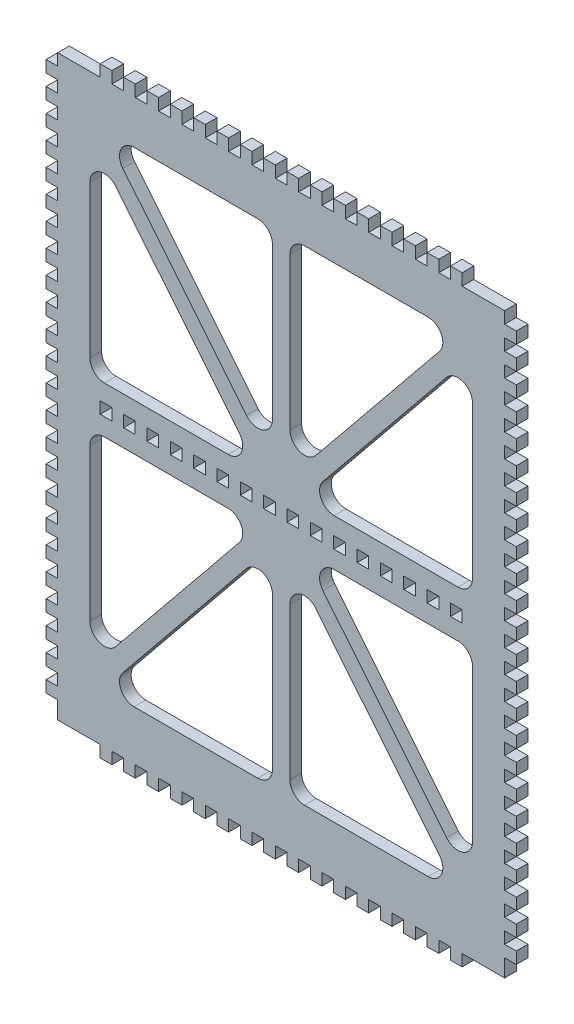
from build123d import *

# Parameters (mm, degrees)
SKETCH1_W           = 161.12
SKETCH1_H           = 198
BOSS_EXTRUDE1_DEPTH = 4
SKETCH2_W           = 4
SKETCH2_H           = 4
SKETCH2_H_2         = 6
CUT_EXTRUDE1_DEPTH  = 4
SKETCH3_W           = 4
SKETCH3_H           = 4
BOSS_EXTRUDE2_DEPTH = 4
SKETCH4_W           = 4
SKETCH4_H           = 4
CUT_EXTRUDE2_DEPTH  = 10


with BuildPart() as part:
    # Sketch1 → Boss-Extrude1 (new body)
    with BuildSketch(Plane.XY):
        with Locations((0, -1)):
            Rectangle(SKETCH1_W, SKETCH1_H)
        with BuildLine():
            Line((-50.394942081, 83), (-8, 83))
            ThreePointArc((-8, 83), (-4.464466094, 81.535533906), (-3, 78))
            Line((-3, 78), (-3, 25.860074887))
            ThreePointArc((-3, 25.860074887), (-6.326255466, 21.148538064), (-11.879431694, 22.705711285))
            Line((-11.879431694, 22.705711285), (-54.274373775, 74.845636398))
            ThreePointArc((-54.274373775, 74.845636398), (-54.910017829, 80.148043527), (-50.394942081, 83))
        make_face(mode=Mode.SUBTRACT)
        with BuildLine():
            Line((-56.680568306, 68.294288715), (-14.285626225, 16.154363602))
            ThreePointArc((-14.285626225, 16.154363602), (-13.649982171, 10.851956473), (-18.165057919, 8))
            Line((-18.165057919, 8), (-60.56, 8))
            ThreePointArc((-60.56, 8), (-64.095533906, 9.464466094), (-65.56, 13))
            Line((-65.56, 13), (-65.56, 65.139925113))
            ThreePointArc((-65.56, 65.139925113), (-62.233744534, 69.851461936), (-56.680568306, 68.294288715))
        make_face(mode=Mode.SUBTRACT)
        with BuildLine():
            Line((8, 83), (50.394942081, 83))
            ThreePointArc((50.394942081, 83), (54.910017829, 80.148043527), (54.274373775, 74.845636398))
            Line((54.274373775, 74.845636398), (11.879431694, 22.705711285))
            ThreePointArc((11.879431694, 22.705711285), (6.326255466, 21.148538064), (3, 25.860074887))
            Line((3, 25.860074887), (3, 78))
            ThreePointArc((3, 78), (4.464466094, 81.535533906), (8, 83))
        make_face(mode=Mode.SUBTRACT)
        with BuildLine():
            Line((56.680568306, 68.294288715), (14.285626225, 16.154363602))
            ThreePointArc((14.285626225, 16.154363602), (13.649982171, 10.851956473), (18.165057919, 8))
            Line((18.165057919, 8), (60.56, 8))
            ThreePointArc((60.56, 8), (64.095533906, 9.464466094), (65.56, 13))
            Line((65.56, 13), (65.56, 65.139925113))
            ThreePointArc((65.56, 65.139925113), (62.233744534, 69.851461936), (56.680568306, 68.294288715))
        make_face(mode=Mode.SUBTRACT)
        with BuildLine():
            Line((-65.56, -13), (-65.56, -65.139925113))
            ThreePointArc((-65.56, -65.139925113), (-62.233744534, -69.851461936), (-56.680568306, -68.294288715))
            Line((-56.680568306, -68.294288715), (-14.285626225, -16.154363602))
            ThreePointArc((-14.285626225, -16.154363602), (-13.649982171, -10.851956473), (-18.165057919, -8))
            Line((-18.165057919, -8), (-60.56, -8))
            ThreePointArc((-60.56, -8), (-64.095533906, -9.464466094), (-65.56, -13))
        make_face(mode=Mode.SUBTRACT)
        with BuildLine():
            Line((65.56, -13), (65.56, -65.139925113))
            ThreePointArc((65.56, -65.139925113), (62.233744534, -69.851461936), (56.680568306, -68.294288715))
            Line((56.680568306, -68.294288715), (14.285626225, -16.154363602))
            ThreePointArc((14.285626225, -16.154363602), (13.649982171, -10.851956473), (18.165057919, -8))
            Line((18.165057919, -8), (60.56, -8))
            ThreePointArc((60.56, -8), (64.095533906, -9.464466094), (65.56, -13))
        make_face(mode=Mode.SUBTRACT)
        with BuildLine():
            Line((11.879431694, -22.705711285), (54.274373775, -74.845636398))
            ThreePointArc((54.274373775, -74.845636398), (54.910017829, -80.148043527), (50.394942081, -83))
            Line((50.394942081, -83), (8, -83))
            ThreePointArc((8, -83), (4.464466094, -81.535533906), (3, -78))
            Line((3, -78), (3, -25.860074887))
            ThreePointArc((3, -25.860074887), (6.326255466, -21.148538064), (11.879431694, -22.705711285))
        make_face(mode=Mode.SUBTRACT)
        with BuildLine():
            Line((-3, -25.860074887), (-3, -78))
            ThreePointArc((-3, -78), (-4.464466094, -81.535533906), (-8, -83))
            Line((-8, -83), (-50.394942081, -83))
            ThreePointArc((-50.394942081, -83), (-54.910017829, -80.148043527), (-54.274373775, -74.845636398))
            Line((-54.274373775, -74.845636398), (-11.879431694, -22.705711285))
            ThreePointArc((-11.879431694, -22.705711285), (-6.326255466, -21.148538064), (-3, -25.860074887))
        make_face(mode=Mode.SUBTRACT)
    extrude(amount=BOSS_EXTRUDE1_DEPTH)

    # Sketch2 → Cut-Extrude1 (cut)
    with BuildSketch(Plane.XY.offset(4)):
        with Locations((-78.56, -48)):
            Rectangle(SKETCH2_W, SKETCH2_H)
        with Locations((-78.56, 88)):
            Rectangle(SKETCH2_W, SKETCH2_H)
        with Locations((-78.56, 80)):
            Rectangle(SKETCH2_W, SKETCH2_H)
        with Locations((-78.56, 72)):
            Rectangle(SKETCH2_W, SKETCH2_H)
        with Locations((-78.56, 64)):
            Rectangle(SKETCH2_W, SKETCH2_H)
        with Locations((-78.56, 56)):
            Rectangle(SKETCH2_W, SKETCH2_H)
        with Locations((-78.56, 48)):
            Rectangle(SKETCH2_W, SKETCH2_H)
        with Locations((-78.56, 40)):
            Rectangle(SKETCH2_W, SKETCH2_H)
        with Locations((-78.56, 32)):
            Rectangle(SKETCH2_W, SKETCH2_H)
        with Locations((-78.56, 24)):
            Rectangle(SKETCH2_W, SKETCH2_H)
        with Locations((-78.56, 16)):
            Rectangle(SKETCH2_W, SKETCH2_H)
        with Locations((-78.56, 8)):
            Rectangle(SKETCH2_W, SKETCH2_H)
        with Locations((-78.56, 0)):
            Rectangle(SKETCH2_W, SKETCH2_H)
        with Locations((-78.56, -8)):
            Rectangle(SKETCH2_W, SKETCH2_H)
        with Locations((-78.56, -16)):
            Rectangle(SKETCH2_W, SKETCH2_H)
        with Locations((-78.56, -24)):
            Rectangle(SKETCH2_W, SKETCH2_H)
        with Locations((-78.56, -32)):
            Rectangle(SKETCH2_W, SKETCH2_H)
        with Locations((-78.56, -40)):
            Rectangle(SKETCH2_W, SKETCH2_H)
        with Locations((78.56, -88)):
            Rectangle(SKETCH2_W, SKETCH2_H)
        with Locations((78.56, -80)):
            Rectangle(SKETCH2_W, SKETCH2_H)
        with Locations((78.56, -72)):
            Rectangle(SKETCH2_W, SKETCH2_H)
        with Locations((78.56, -64)):
            Rectangle(SKETCH2_W, SKETCH2_H)
        with Locations((78.56, -56)):
            Rectangle(SKETCH2_W, SKETCH2_H)
        with Locations((78.56, -48)):
            Rectangle(SKETCH2_W, SKETCH2_H)
        with Locations((78.56, 96)):
            Rectangle(SKETCH2_W, SKETCH2_H)
        with Locations((78.56, -40)):
            Rectangle(SKETCH2_W, SKETCH2_H)
        with Locations((-78.56, 96)):
            Rectangle(SKETCH2_W, SKETCH2_H)
        with Locations((78.56, -32)):
            Rectangle(SKETCH2_W, SKETCH2_H)
        with Locations((78.56, -24)):
            Rectangle(SKETCH2_W, SKETCH2_H)
        with Locations((78.56, -16)):
            Rectangle(SKETCH2_W, SKETCH2_H)
        with Locations((78.56, -8)):
            Rectangle(SKETCH2_W, SKETCH2_H)
        with Locations((78.56, 0)):
            Rectangle(SKETCH2_W, SKETCH2_H)
        with Locations((78.56, 8)):
            Rectangle(SKETCH2_W, SKETCH2_H)
        with Locations((78.56, 16)):
            Rectangle(SKETCH2_W, SKETCH2_H)
        with Locations((78.56, 24)):
            Rectangle(SKETCH2_W, SKETCH2_H)
        with Locations((78.56, 32)):
            Rectangle(SKETCH2_W, SKETCH2_H)
        with Locations((78.56, 40)):
            Rectangle(SKETCH2_W, SKETCH2_H)
        with Locations((78.56, 48)):
            Rectangle(SKETCH2_W, SKETCH2_H)
        with Locations((-78.56, -56)):
            Rectangle(SKETCH2_W, SKETCH2_H)
        with Locations((-78.56, -64)):
            Rectangle(SKETCH2_W, SKETCH2_H)
        with Locations((-78.56, -72)):
            Rectangle(SKETCH2_W, SKETCH2_H)
        with Locations((-78.56, -80)):
            Rectangle(SKETCH2_W, SKETCH2_H)
        with Locations((-78.56, -88)):
            Rectangle(SKETCH2_W, SKETCH2_H)
        with Locations((78.56, 56)):
            Rectangle(SKETCH2_W, SKETCH2_H)
        with Locations((78.56, 64)):
            Rectangle(SKETCH2_W, SKETCH2_H)
        with Locations((78.56, 72)):
            Rectangle(SKETCH2_W, SKETCH2_H)
        with Locations((78.56, 80)):
            Rectangle(SKETCH2_W, SKETCH2_H)
        with Locations((78.56, 88)):
            Rectangle(SKETCH2_W, SKETCH2_H)
        with Locations((-78.56, -97)):
            Rectangle(SKETCH2_W, SKETCH2_H_2)
        with Locations((78.56, -97)):
            Rectangle(SKETCH2_W, SKETCH2_H_2)
    extrude(amount=-CUT_EXTRUDE1_DEPTH, mode=Mode.SUBTRACT)

    # Sketch3 → Boss-Extrude2 (add)
    with BuildSketch(Plane.XY.offset(4)):
        with Locations((-4, 100)):
            Rectangle(SKETCH3_W, SKETCH3_H)
        with Locations((-12, 100)):
            Rectangle(SKETCH3_W, SKETCH3_H)
        with Locations((-20, 100)):
            Rectangle(SKETCH3_W, SKETCH3_H)
        with Locations((-28, 100)):
            Rectangle(SKETCH3_W, SKETCH3_H)
        with Locations((-36, 100)):
            Rectangle(SKETCH3_W, SKETCH3_H)
        with Locations((-44, 100)):
            Rectangle(SKETCH3_W, SKETCH3_H)
        with Locations((-52, 100)):
            Rectangle(SKETCH3_W, SKETCH3_H)
        with Locations((-60, 100)):
            Rectangle(SKETCH3_W, SKETCH3_H)
        with Locations((60, 100)):
            Rectangle(SKETCH3_W, SKETCH3_H)
        with Locations((52, 100)):
            Rectangle(SKETCH3_W, SKETCH3_H)
        with Locations((44, 100)):
            Rectangle(SKETCH3_W, SKETCH3_H)
        with Locations((36, 100)):
            Rectangle(SKETCH3_W, SKETCH3_H)
        with Locations((28, 100)):
            Rectangle(SKETCH3_W, SKETCH3_H)
        with Locations((20, 100)):
            Rectangle(SKETCH3_W, SKETCH3_H)
        with Locations((12, 100)):
            Rectangle(SKETCH3_W, SKETCH3_H)
        with Locations((4, 100)):
            Rectangle(SKETCH3_W, SKETCH3_H)
        with Locations((4, -102)):
            Rectangle(SKETCH3_W, SKETCH3_H)
        with Locations((12, -102)):
            Rectangle(SKETCH3_W, SKETCH3_H)
        with Locations((20, -102)):
            Rectangle(SKETCH3_W, SKETCH3_H)
        with Locations((28, -102)):
            Rectangle(SKETCH3_W, SKETCH3_H)
        with Locations((36, -102)):
            Rectangle(SKETCH3_W, SKETCH3_H)
        with Locations((44, -102)):
            Rectangle(SKETCH3_W, SKETCH3_H)
        with Locations((52, -102)):
            Rectangle(SKETCH3_W, SKETCH3_H)
        with Locations((60, -102)):
            Rectangle(SKETCH3_W, SKETCH3_H)
        with Locations((-60, -102)):
            Rectangle(SKETCH3_W, SKETCH3_H)
        with Locations((-52, -102)):
            Rectangle(SKETCH3_W, SKETCH3_H)
        with Locations((-44, -102)):
            Rectangle(SKETCH3_W, SKETCH3_H)
        with Locations((-36, -102)):
            Rectangle(SKETCH3_W, SKETCH3_H)
        with Locations((-28, -102)):
            Rectangle(SKETCH3_W, SKETCH3_H)
        with Locations((-20, -102)):
            Rectangle(SKETCH3_W, SKETCH3_H)
        with Locations((-12, -102)):
            Rectangle(SKETCH3_W, SKETCH3_H)
        with Locations((-4, -102)):
            Rectangle(SKETCH3_W, SKETCH3_H)
    extrude(amount=-BOSS_EXTRUDE2_DEPTH)

    # Sketch4 → Cut-Extrude2 (cut)
    with BuildSketch(Plane.XY.offset(4)):
        with Locations((12, 0)):
            Rectangle(SKETCH4_W, SKETCH4_H)
        with Locations((4, 0)):
            Rectangle(SKETCH4_W, SKETCH4_H)
        with Locations((20, 0)):
            Rectangle(SKETCH4_W, SKETCH4_H)
        with Locations((28, 0)):
            Rectangle(SKETCH4_W, SKETCH4_H)
        with Locations((36, 0)):
            Rectangle(SKETCH4_W, SKETCH4_H)
        with Locations((44, 0)):
            Rectangle(SKETCH4_W, SKETCH4_H)
        with Locations((52, 0)):
            Rectangle(SKETCH4_W, SKETCH4_H)
        with Locations((60, 0)):
            Rectangle(SKETCH4_W, SKETCH4_H)
        with Locations((-60, 0)):
            Rectangle(SKETCH4_W, SKETCH4_H)
        with Locations((-52, 0)):
            Rectangle(SKETCH4_W, SKETCH4_H)
        with Locations((-44, 0)):
            Rectangle(SKETCH4_W, SKETCH4_H)
        with Locations((-36, 0)):
            Rectangle(SKETCH4_W, SKETCH4_H)
        with Locations((-28, 0)):
            Rectangle(SKETCH4_W, SKETCH4_H)
        with Locations((-20, 0)):
            Rectangle(SKETCH4_W, SKETCH4_H)
        with Locations((-12, 0)):
            Rectangle(SKETCH4_W, SKETCH4_H)
        with Locations((-4, 0)):
            Rectangle(SKETCH4_W, SKETCH4_H)
    extrude(amount=-CUT_EXTRUDE2_DEPTH, mode=Mode.SUBTRACT)


solid = part.part
